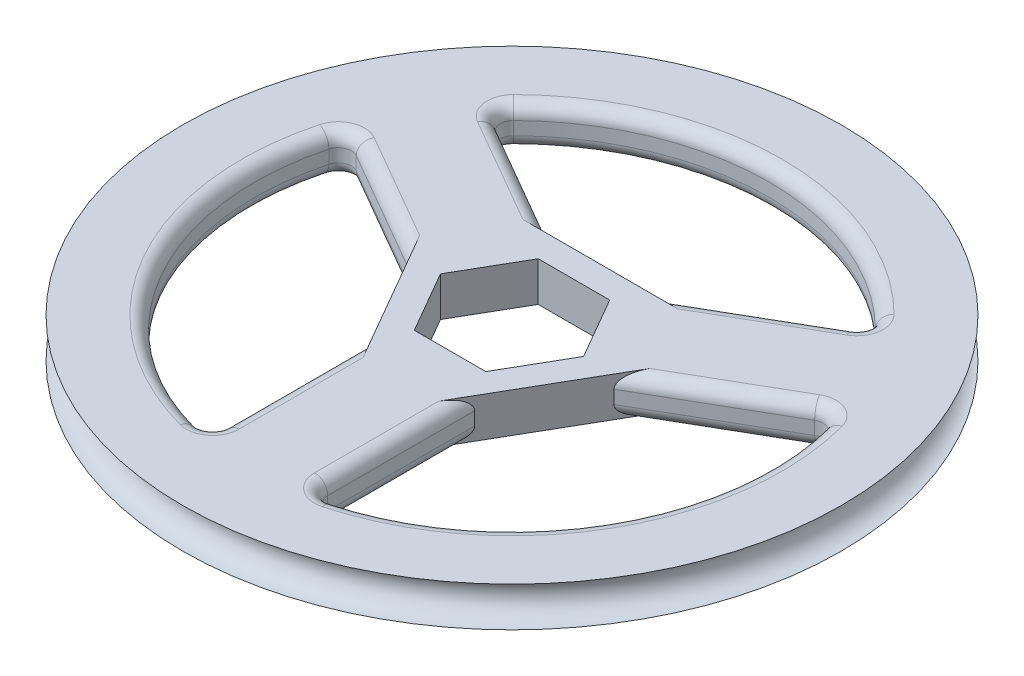
from build123d import *

# Parameters (mm, degrees)
SKETCH1_R           = 31.75
SKETCH1_R_2         = 24.765
BOSS_EXTRUDE1_DEPTH = 3.81
FILLET2_R           = 1.27


with BuildPart() as part:
    # Sketch1 → Boss-Extrude1 (new body)
    with BuildSketch(Plane(origin=(0, 0, 0), x_dir=(1, 0, 0), z_dir=(0, 1, 0))):
        Circle(SKETCH1_R)
        Circle(SKETCH1_R_2, mode=Mode.SUBTRACT)
        with BuildLine():
            Line((4.912673441, -8.509), (-4.912673441, -8.509))
            Line((-4.912673441, -8.509), (-4.912673441, -24.272842122))
            ThreePointArc((-4.912673441, -24.272842122), (0, -24.765), (4.912673441, -24.272842122))
            Line((4.912673441, -24.272842122), (4.912673441, -8.509))
        make_face()
        with BuildLine():
            Line((-23.47723462, 7.881921061), (-9.825346881, 0))
            Line((-9.825346881, 0), (-4.912673441, 8.509))
            Line((-4.912673441, 8.509), (-18.564561179, 16.390921061))
            ThreePointArc((-18.564561179, 16.390921061), (-21.447119125, 12.3825), (-23.47723462, 7.881921061))
        make_face()
        with BuildLine():
            Line((4.912673441, 8.509), (9.825346881, 0))
            Line((9.825346881, 0), (23.47723462, 7.881921061))
            ThreePointArc((23.47723462, 7.881921061), (21.447119125, 12.3825), (18.564561179, 16.390921061))
            Line((18.564561179, 16.390921061), (4.912673441, 8.509))
        make_face()
        Polygon((-4.912673441, 8.509), (-9.825346881, 0), (-4.912673441, -8.509), (4.912673441, -8.509), (9.825346881, 0), (4.912673441, 8.509), align=None)
        Polygon((6.892407514, 0), (3.446203757, 5.969), (-3.446203757, 5.969), (-6.892407514, 0), (-3.446203757, -5.969), (3.446203757, -5.969), align=None, mode=Mode.SUBTRACT)
    extrude(amount=BOSS_EXTRUDE1_DEPTH)

    # Sketch5 → Cut-Revolve4 (revolve, cut)
    with BuildSketch(Plane(origin=(0, 0, 0), x_dir=(0, 0, -1), z_dir=(1, 0, 0))):
        with BuildLine():
            Line((-31.75, 3.81), (-31.75, 0))
            ThreePointArc((-31.75, 0), (-29.845, 1.905), (-31.75, 3.81))
        make_face()
    revolve(axis=Axis((0, 3.81, 0), (0, -1, 0)), mode=Mode.SUBTRACT)

    # Fillet2
    fillet2_edges = [part.edges().sort_by_distance(p)[0] for p in [
        (-4.912673441, 3.81, 16.390921061),
        (-21.447119125, 3.81, 12.3825),
        (16.65129075, 0, -3.94096053),
        (11.73861731, 3.81, -12.44996053),
        (4.912673441, 0, 16.390921061),
        (21.447119125, 0, 12.3825),
        (0, 0, -24.765),
        (-11.73861731, 0, -12.44996053),
        (11.73861731, 0, -12.44996053),
        (-21.447119125, 0, 12.3825),
        (-4.912673441, 0, 16.390921061),
        (-16.65129075, 0, -3.94096053),
        (-11.73861731, 3.81, -12.44996053),
        (23.47723462, 1.905, -7.881921061),
        (4.912673441, 1.905, 24.272842122),
        (0, 3.81, -24.765),
        (18.564561179, 1.905, -16.390921061),
        (-18.564561179, 1.905, -16.390921061),
        (-23.47723462, 1.905, -7.881921061),
        (-4.912673441, 1.905, 24.272842122),
        (21.447119125, 3.81, 12.3825),
        (4.912673441, 3.81, 16.390921061),
        (16.65129075, 3.81, -3.94096053),
        (-16.65129075, 3.81, -3.94096053),
    ]]
    fillet(fillet2_edges, radius=FILLET2_R)


solid = part.part
